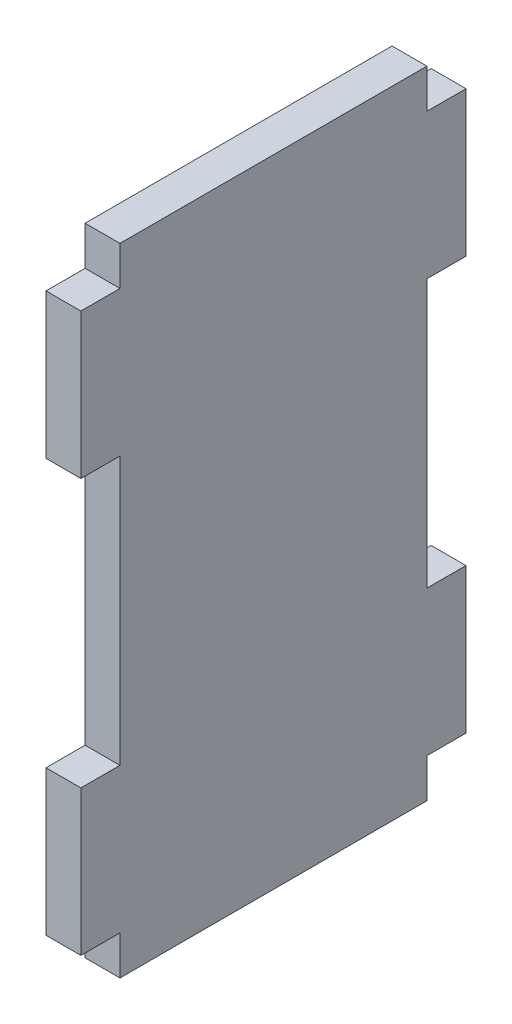
from build123d import *

# Parameters (mm, degrees)
SKETCH1_W           = 276
SKETCH1_H           = 456
BOSS_EXTRUDE1_DEPTH = 25
SKETCH2_W           = 28
SKETCH2_H           = 28
SKETCH2_H_2         = 192
CUT_EXTRUDE1_DEPTH  = 25


with BuildPart() as part:
    # Sketch1 → Boss-Extrude1 (new body)
    with BuildSketch(Plane(origin=(0, 0, 0), x_dir=(0, 0, -1), z_dir=(1, 0, 0))):
        with Locations((-123.692307692, 18.538461538)):
            Rectangle(SKETCH1_W, SKETCH1_H)
    extrude(amount=BOSS_EXTRUDE1_DEPTH)

    # Sketch2 → Cut-Extrude1 (cut)
    with BuildSketch(Plane(origin=(0, 0, 0), x_dir=(0, 0, -1), z_dir=(1, 0, 0))):
        with Locations((0.307692308, -195.461538462)):
            Rectangle(SKETCH2_W, SKETCH2_H)
        with Locations((-247.692307692, -195.461538462)):
            Rectangle(SKETCH2_W, SKETCH2_H)
        with Locations((0.307692308, 232.538461538)):
            Rectangle(SKETCH2_W, SKETCH2_H)
        with Locations((-247.692307692, 232.538461538)):
            Rectangle(SKETCH2_W, SKETCH2_H)
        with Locations((0.307692308, 18.538461538)):
            Rectangle(SKETCH2_W, SKETCH2_H_2)
        with Locations((-247.692307692, 18.538461538)):
            Rectangle(SKETCH2_W, SKETCH2_H_2)
    extrude(amount=CUT_EXTRUDE1_DEPTH, mode=Mode.SUBTRACT)


solid = part.part
